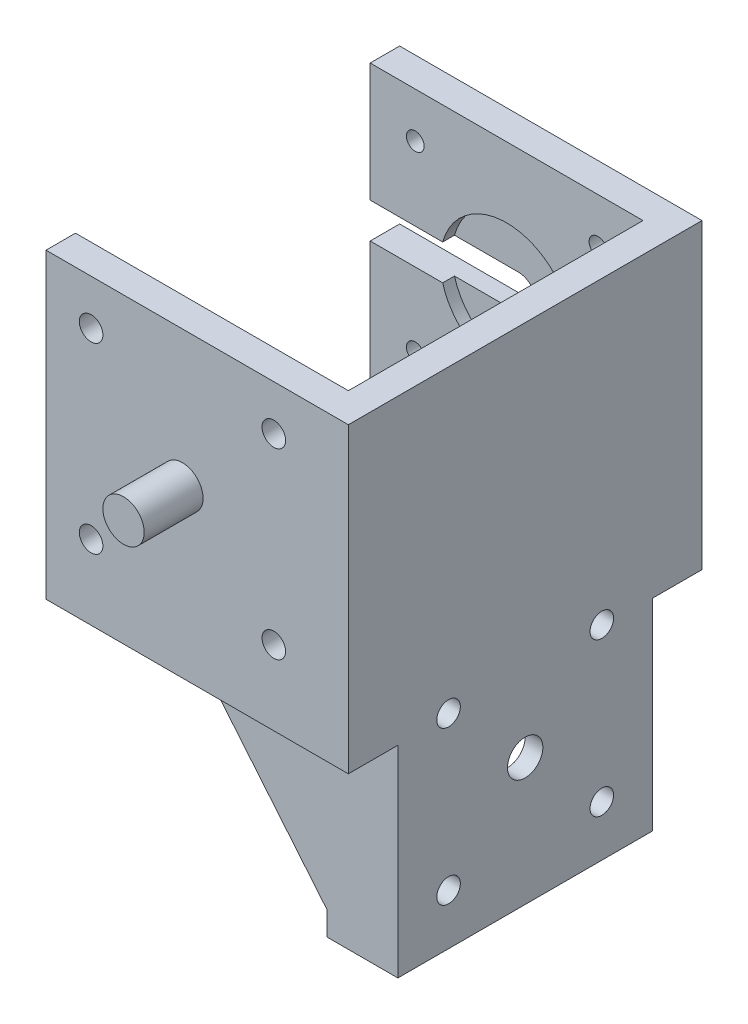
from build123d import *

# Parameters (mm, degrees)
BOSS_EXTRUDE1_DEPTH  = 46.3
SKETCH3_R            = 11.25
CUT_EXTRUDE2_DEPTH   = 2
SKETCH3_5_R          = 1.5
SKETCH3_5_R_2        = 3
CUT_EXTRUDE3_DEPTH   = 5
SKETCH4_R            = 2
CUT_EXTRUDE4_DEPTH   = 5
SKETCH5_W            = 5
SKETCH5_H            = 35.2
BOSS_EXTRUDE2_DEPTH  = 35.2
BOSS_EXTRUDE4_DEPTH  = 12
SKETCH8_R            = 2
SKETCH8_R_2          = 3
CUT_EXTRUDE5_DEPTH   = 5
SKETCH8_3_R          = 11
CUT_EXTRUDE6_DEPTH   = 2
SKETCH10_W           = 51.3
SKETCH10_H           = 12.4
BOSS_EXTRUDE8_DEPTH  = 5
SKETCH11_W           = 51.3
SKETCH11_H           = 12.4
BOSS_EXTRUDE9_DEPTH  = 5
BOSS_EXTRUDE10_DEPTH = 4
BOSS_EXTRUDE11_DEPTH = 4
SKETCH15_W           = 23.15
SKETCH15_H           = 6
CUT_EXTRUDE7_DEPTH   = 5
SKETCH18_R           = 3.5
BOSS_EXTRUDE12_DEPTH = 15


with BuildPart() as part:
    # Sketch1 → Boss-Extrude1 (new body)
    with BuildSketch(Plane(origin=(0, 0, 0), x_dir=(1, 0, 0), z_dir=(0, 1, 0))):
        Polygon((0, 0), (46.3, 0), (46.3, 50), (0, 50), (0, 55), (51.3, 55), (51.3, -5), (0, -5), align=None)
    extrude(amount=BOSS_EXTRUDE1_DEPTH)

    # Sketch3 → Cut-Extrude2 (cut)
    with BuildSketch(Plane.XY.offset(-50)):
        with Locations((23.15, 23.15)):
            Circle(SKETCH3_R)
    extrude(amount=-CUT_EXTRUDE2_DEPTH, mode=Mode.SUBTRACT)

    # Sketch3_5 → Cut-Extrude3 (cut)
    with BuildSketch(Plane.XY.offset(-50)):
        with Locations((38.65, 38.65)):
            Circle(SKETCH3_5_R)
        with Locations((7.65, 38.65)):
            Circle(SKETCH3_5_R)
        with Locations((7.65, 7.65)):
            Circle(SKETCH3_5_R)
        with Locations((38.65, 7.65)):
            Circle(SKETCH3_5_R)
        with Locations((23.15, 23.15)):
            Circle(SKETCH3_5_R_2)
    extrude(amount=-CUT_EXTRUDE3_DEPTH, mode=Mode.SUBTRACT)

    # Sketch4 → Cut-Extrude4 (cut)
    with BuildSketch(Plane(origin=(0, 0, 0), x_dir=(-1, 0, 0), z_dir=(0, 0, -1))):
        with Locations((-7.65, 7.65)):
            Circle(SKETCH4_R)
        with Locations((-7.65, 38.65)):
            Circle(SKETCH4_R)
        with Locations((-38.65, 7.65)):
            Circle(SKETCH4_R)
        with Locations((-38.65, 38.65)):
            Circle(SKETCH4_R)
    extrude(amount=-CUT_EXTRUDE4_DEPTH, mode=Mode.SUBTRACT)

    # Sketch5 → Boss-Extrude2 (add)
    with BuildSketch(Plane.XZ):
        with Locations((48.8, -25)):
            Rectangle(SKETCH5_W, SKETCH5_H)
    extrude(amount=BOSS_EXTRUDE2_DEPTH)

    # Sketch6 → Boss-Extrude4 (add)
    with BuildSketch(Plane(origin=(51.3, 0, 0), x_dir=(0, 0, -1), z_dir=(1, 0, 0))):
        Polygon((7.4, 0), (3.4, 0), (3.4, -39.2), (46.6, -39.2), (46.6, 0), (42.6, 0), (42.6, -35.2), (7.4, -35.2), align=None)
    extrude(amount=-BOSS_EXTRUDE4_DEPTH)

    # Sketch8 → Cut-Extrude5 (cut)
    with BuildSketch(Plane.ZY.offset(-46.3)):
        with Locations((-12, -4.6)):
            Circle(SKETCH8_R)
        with Locations((-38, -4.6)):
            Circle(SKETCH8_R)
        with Locations((-38, -30.6)):
            Circle(SKETCH8_R)
        with Locations((-12, -30.6)):
            Circle(SKETCH8_R)
        with Locations((-25, -17.6)):
            Circle(SKETCH8_R_2)
    extrude(amount=-CUT_EXTRUDE5_DEPTH, mode=Mode.SUBTRACT)

    # Sketch8_3 → Cut-Extrude6 (cut)
    with BuildSketch(Plane.ZY.offset(-46.3)):
        with Locations((-25, -17.6)):
            Circle(SKETCH8_3_R)
    extrude(amount=-CUT_EXTRUDE6_DEPTH, mode=Mode.SUBTRACT)

    # Sketch10 → Boss-Extrude8 (add)
    with BuildSketch(Plane.XZ):
        with Locations((25.65, -1.2)):
            Rectangle(SKETCH10_W, SKETCH10_H)
    extrude(amount=BOSS_EXTRUDE8_DEPTH)

    # Sketch11 → Boss-Extrude9 (add)
    with BuildSketch(Plane.XZ):
        with Locations((25.65, -48.8)):
            Rectangle(SKETCH11_W, SKETCH11_H)
    extrude(amount=BOSS_EXTRUDE9_DEPTH)

    # Sketch12 → Boss-Extrude10 (add)
    with BuildSketch(Plane.XY.offset(-42.6)):
        Polygon((39.3, -5), (14.3, -5), (39.3, -35.2), align=None)
    extrude(amount=-BOSS_EXTRUDE10_DEPTH)

    # Sketch13 → Boss-Extrude11 (add)
    with BuildSketch(Plane(origin=(0, 0, -7.4), x_dir=(-1, 0, 0), z_dir=(0, 0, -1))):
        Polygon((-39.3, -5), (-14.3, -5), (-39.3, -35.2), align=None)
    extrude(amount=-BOSS_EXTRUDE11_DEPTH)

    # Sketch15 → Cut-Extrude7 (cut)
    with BuildSketch(Plane(origin=(0, 0, -55), x_dir=(-1, 0, 0), z_dir=(0, 0, -1))):
        with Locations((-11.575, 23.15)):
            Rectangle(SKETCH15_W, SKETCH15_H)
    extrude(amount=-CUT_EXTRUDE7_DEPTH, mode=Mode.SUBTRACT)

    # Sketch18 → Boss-Extrude12 (add)
    with BuildSketch(Plane(origin=(0, 0, 0), x_dir=(-1, 0, 0), z_dir=(0, 0, -1))):
        with Locations((-23.15, 23.15)):
            Circle(SKETCH18_R)
    extrude(amount=-BOSS_EXTRUDE12_DEPTH)


solid = part.part
